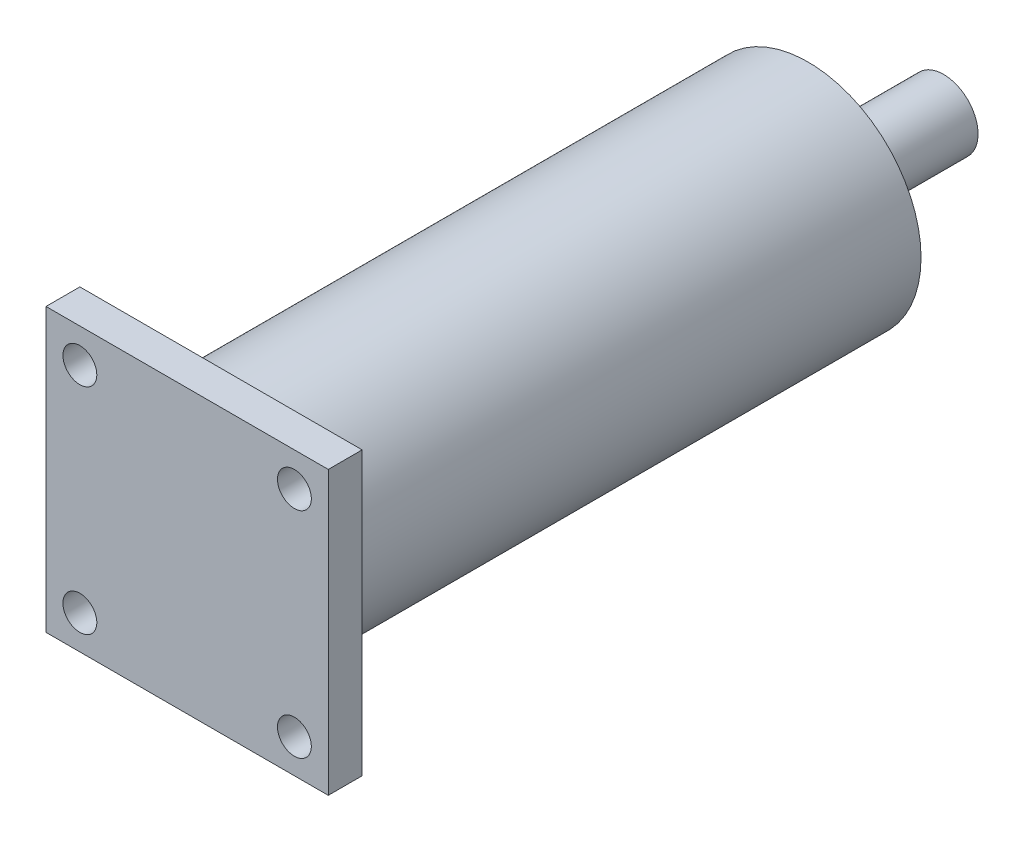
from build123d import *

# Parameters (mm, degrees)
SKETCH_2_W          = 25
SKETCH_2_H          = 25
EXTRUDE_1_DEPTH     = 3
SKETCH_3_R          = 1.5
CUT_EXTRUDE_2_DEPTH = 4
EXTRUDE_START       = -3
SKETCH_4_R          = 10
EXTRUDE_2_DEPTH     = 52
SKETCH_5_R          = 3.05
EXTRUDE_3_DEPTH     = 12


with BuildPart() as part:
    # 草图2 → 凸台-拉伸1 (new body)
    with BuildSketch(Plane.XY):
        with Locations((12.5, -12.5)):
            Rectangle(SKETCH_2_W, SKETCH_2_H)
    extrude(amount=EXTRUDE_1_DEPTH)

    # 草图3 → 切除-拉伸2 (cut, through all)
    with BuildSketch(Plane(origin=(0, 0, 0), x_dir=(-1, 0, 0), z_dir=(0, 0, -1))):
        with Locations((-22, -3)):
            Circle(SKETCH_3_R)
        with Locations((-3, -3)):
            Circle(SKETCH_3_R)
        with Locations((-3, -22)):
            Circle(SKETCH_3_R)
        with Locations((-22, -22)):
            Circle(SKETCH_3_R)
    extrude(amount=-CUT_EXTRUDE_2_DEPTH, mode=Mode.SUBTRACT)

    # 草图4 → 凸台-拉伸2 (add)
    with BuildSketch(Plane.XY.offset(3).offset(EXTRUDE_START)):
        with Locations((12.5, -12.5)):
            Circle(SKETCH_4_R)
    extrude(amount=-EXTRUDE_2_DEPTH)

    # 草图5 → 凸台-拉伸3 (add)
    with BuildSketch(Plane(origin=(0, 0, -52), x_dir=(-1, 0, 0), z_dir=(0, 0, -1))):
        with Locations((-12.5, -12.5)):
            Circle(SKETCH_5_R)
    extrude(amount=EXTRUDE_3_DEPTH)


solid = part.part
